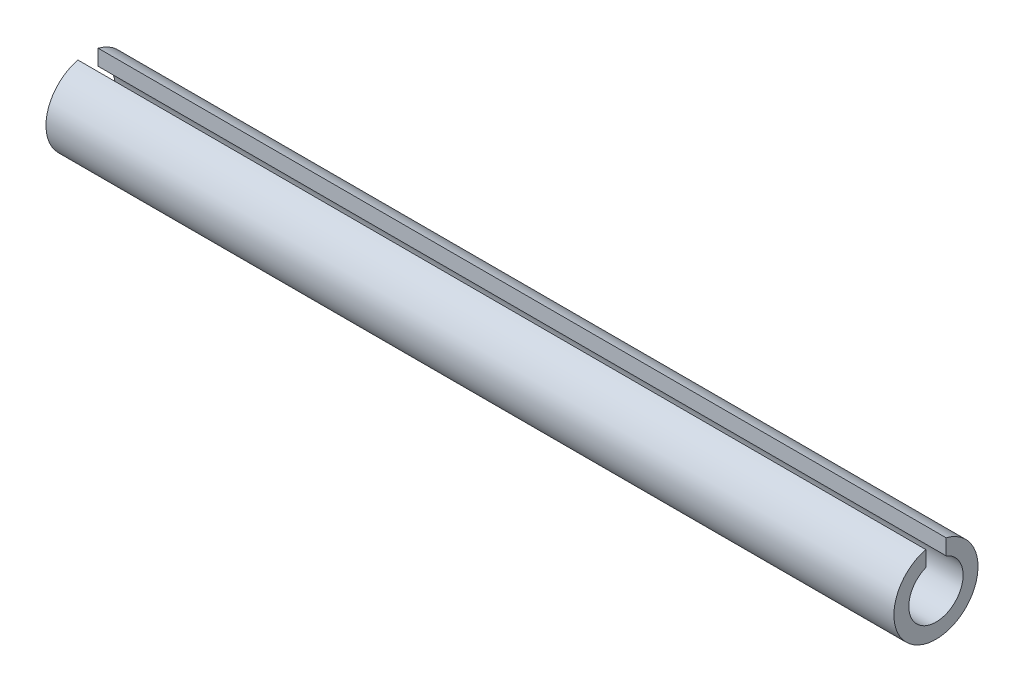
from build123d import *

# Parameters (mm, degrees)
BOSS_EXTRUDE1_DEPTH = 15.875


with BuildPart() as part:
    # Sketch1 → Boss-Extrude1 (new body)
    with BuildSketch(Plane(origin=(0, 0, 0), x_dir=(0, 0, -1), z_dir=(1, 0, 0))):
        with BuildLine():
            Line((0.1905, 0.470928604), (0.1905, 0.764008187))
            ThreePointArc((0.1905, 0.764008187), (0, -0.7874), (-0.1905, 0.764008187))
            Line((-0.1905, 0.764008187), (-0.1905, 0.470928604))
            ThreePointArc((-0.1905, 0.470928604), (0, -0.508), (0.1905, 0.470928604))
        make_face()
    extrude(amount=BOSS_EXTRUDE1_DEPTH)


solid = part.part
